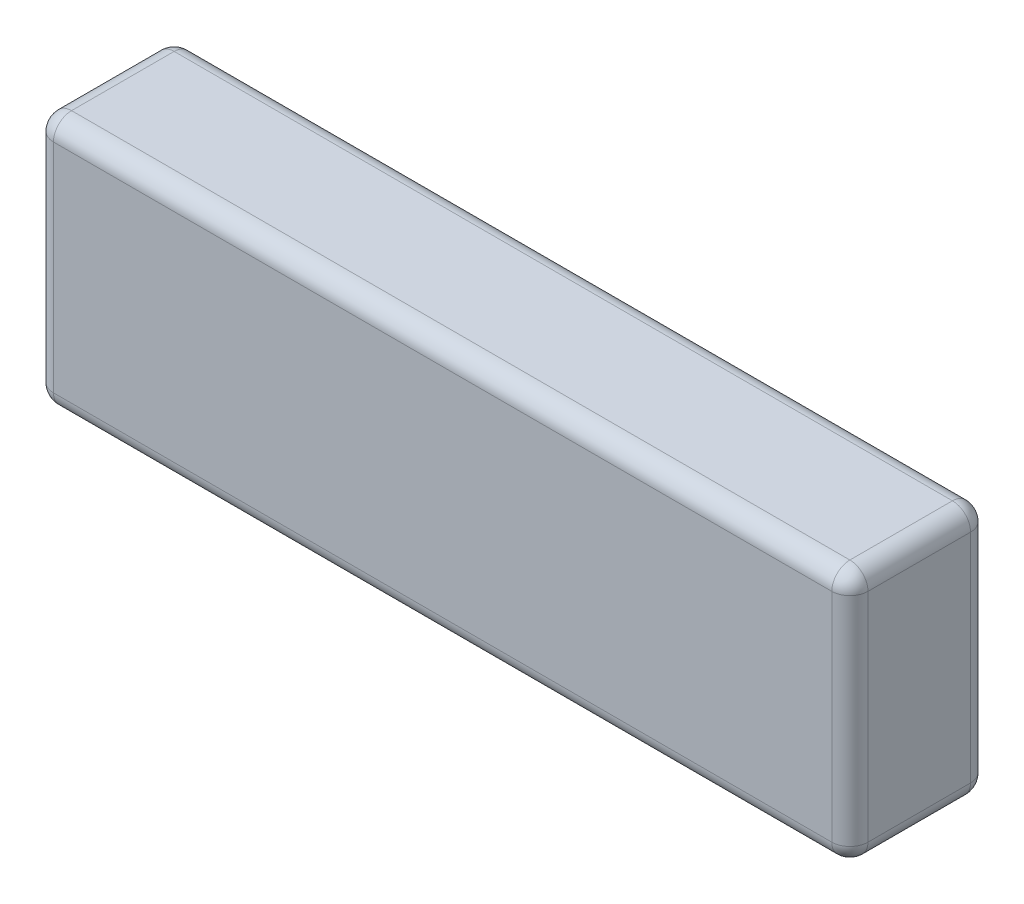
from build123d import *

# Parameters (mm, degrees)
ESBO_O1_W                = 135
ESBO_O1_H                = 42
RESSALTO_EXTRUS_O1_DEPTH = 11.5
FILETE1_R                = 3


with BuildPart() as part:
    # Esboço1 → Ressalto-extrusão1 (new body, symmetric)
    with BuildSketch(Plane.XY):
        Rectangle(ESBO_O1_W, ESBO_O1_H)
    extrude(amount=RESSALTO_EXTRUS_O1_DEPTH, both=True)

    # Filete1
    filete1_edges = [part.edges().sort_by_distance(p)[0] for p in [
        (-67.5, 0, 11.5),
        (0, -21, 11.5),
        (67.5, 0, 11.5),
        (0, -21, -11.5),
        (-67.5, 0, -11.5),
        (0, 21, -11.5),
        (67.5, 0, -11.5),
        (0, 21, 11.5),
        (67.5, -21, 0),
        (-67.5, -21, 0),
        (-67.5, 21, 0),
        (67.5, 21, 0),
    ]]
    fillet(filete1_edges, radius=FILETE1_R)


solid = part.part
